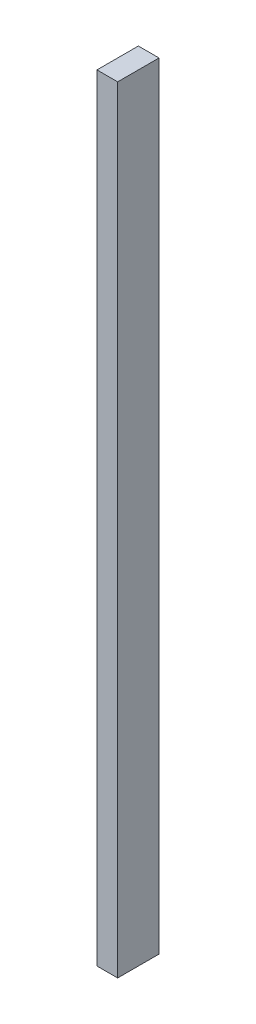
from build123d import *

# Parameters (mm, degrees)
SKETCH1_W           = 0.8
SKETCH1_H           = 30
BOSS_EXTRUDE1_DEPTH = 1.6


with BuildPart() as part:
    # Sketch1 → Boss-Extrude1 (new body)
    with BuildSketch(Plane.XY):
        with Locations((-0.4, 15)):
            Rectangle(SKETCH1_W, SKETCH1_H)
    extrude(amount=BOSS_EXTRUDE1_DEPTH)


solid = part.part
